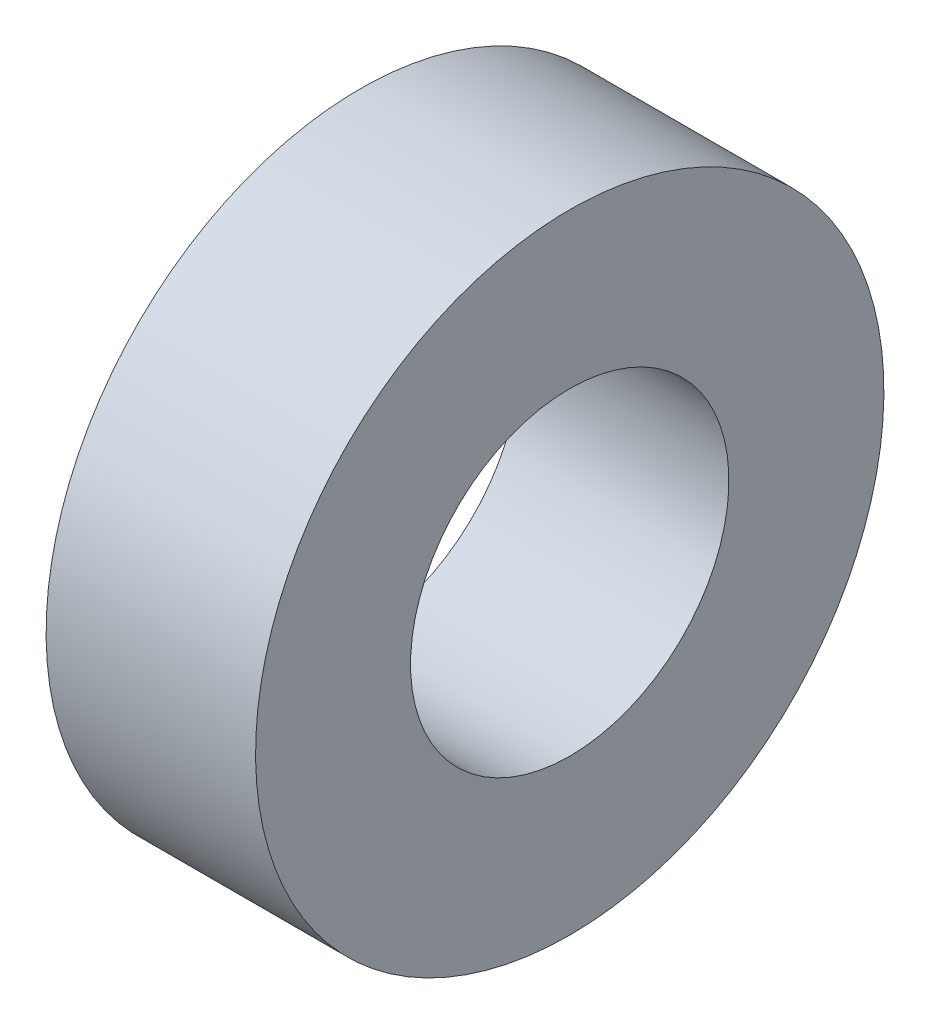
from build123d import *

# Parameters (mm, degrees)
SKETCH1_W = 3.175
SKETCH1_H = 2.3495


with BuildPart() as part:
    # Sketch1 → Revolve1 (revolve)
    with BuildSketch(Plane.XY):
        with Locations((1.5875, 3.58775)):
            Rectangle(SKETCH1_W, SKETCH1_H)
    revolve(axis=Axis((0, 0, 0), (1, 0, 0)))


solid = part.part
